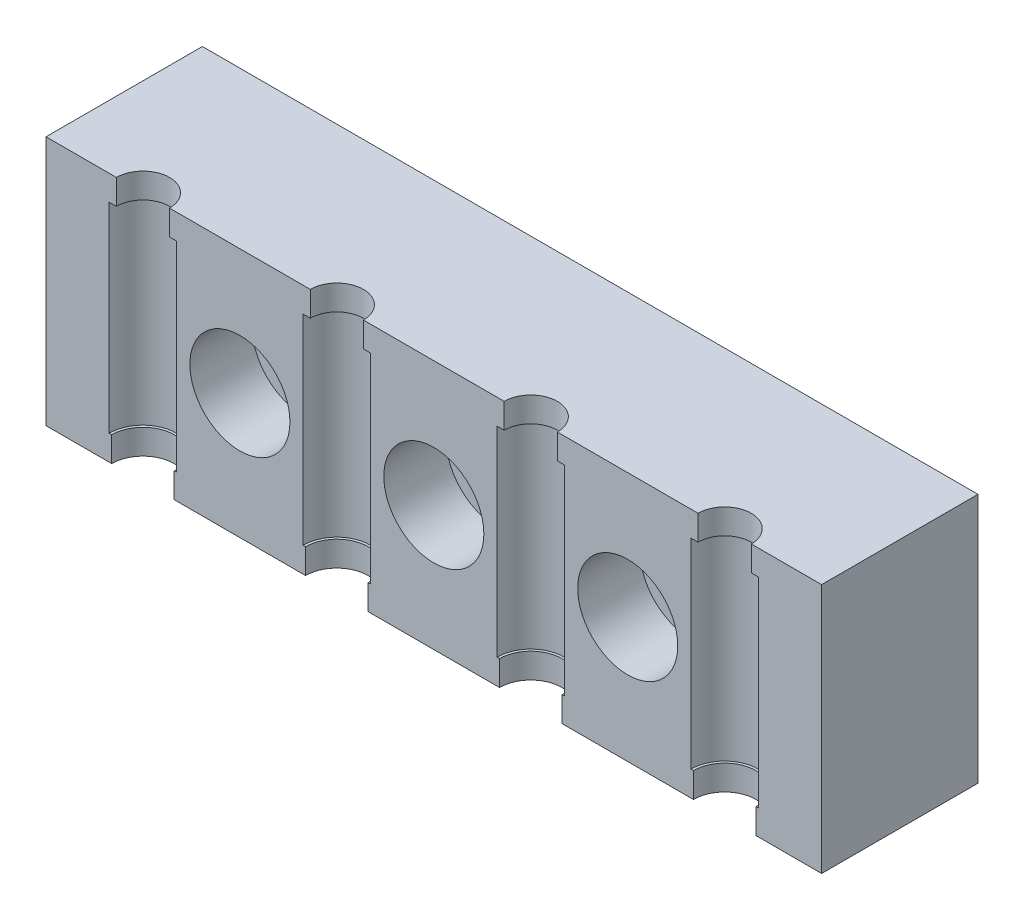
from build123d import *

# Parameters (mm, degrees)
WYCI_GNI_CIE1_DEPTH        = 62
SZKIC2_R                   = 2.125
WYTNIJ_WYCI_GNI_CIE1_DEPTH = 21
SZKIC3_R                   = 2.7
WYTNIJ_WYCI_GNI_CIE2_DEPTH = 16
SZKIC4_W                   = 5
SZKIC4_H                   = 2
WYTNIJ_WYCI_GNI_CIE3_DEPTH = 21
SFAZOWANIE1_SIZE           = 0.5
SZKIC5_R                   = 2.5
WYTNIJ_WYCI_GNI_CIE4_DEPTH = 16
SZKIC6_R                   = 4
WYTNIJ_WYCI_GNI_CIE5_DEPTH = 5
SZKIC7_R                   = 2.5
WYTNIJ_WYCI_GNI_CIE6_DEPTH = 10


with BuildPart() as part:
    # Szkic1 → Wyciągnięcie1 (new body)
    with BuildSketch(Plane(origin=(0, 0, 0), x_dir=(0, 0, -1), z_dir=(1, 0, 0))):
        Polygon((0, 0), (0, -20), (13, -20), (13, -15), (15, -15), (15, -5), (13, -5), (13, 0), align=None)
    extrude(amount=WYCI_GNI_CIE1_DEPTH)

    # Szkic2 → Wytnij-wyciągnięcie1 (cut, through all)
    with BuildSketch(Plane(origin=(0, 0, 0), x_dir=(-1, 0, 0), z_dir=(0, 1, 0))):
        with Locations((-7.75, 0)):
            Circle(SZKIC2_R)
        with Locations((-23.25, 0)):
            Circle(SZKIC2_R)
        with Locations((-38.75, 0)):
            Circle(SZKIC2_R)
        with Locations((-54.25, 0)):
            Circle(SZKIC2_R)
    extrude(amount=-WYTNIJ_WYCI_GNI_CIE1_DEPTH, mode=Mode.SUBTRACT)

    # Szkic3 → Wytnij-wyciągnięcie2 (cut)
    with BuildSketch(Plane(origin=(0, -2, 0), x_dir=(-1, 0, 0), z_dir=(0, 1, 0))):
        with Locations((-7.75, 0)):
            Circle(SZKIC3_R)
        with Locations((-23.25, 0)):
            Circle(SZKIC3_R)
        with Locations((-38.75, 0)):
            Circle(SZKIC3_R)
        with Locations((-54.25, 0)):
            Circle(SZKIC3_R)
    extrude(amount=-WYTNIJ_WYCI_GNI_CIE2_DEPTH, mode=Mode.SUBTRACT)

    # Szkic4 → Wytnij-wyciągnięcie3 (cut, through all)
    with BuildSketch(Plane(origin=(0, 0, 0), x_dir=(-1, 0, 0), z_dir=(0, 1, 0))):
        with Locations((-59.5, -14)):
            Rectangle(SZKIC4_W, SZKIC4_H)
        with Locations((-2.5, -14)):
            Rectangle(SZKIC4_W, SZKIC4_H)
    extrude(amount=-WYTNIJ_WYCI_GNI_CIE3_DEPTH, mode=Mode.SUBTRACT)

    # Sfazowanie1
    sfazowanie1_edges = [part.edges().sort_by_distance(p)[0] for p in [
        (31, -5, -15),
        (31, -15, -15),
        (57, -10, -15),
        (31, 0, -13),
        (62, -10, -13),
        (31, -20, -13),
        (5, -10, -15),
        (0, -10, -13),
    ]]
    chamfer(sfazowanie1_edges, length=SFAZOWANIE1_SIZE)

    # Szkic5 → Wytnij-wyciągnięcie4 (cut, through all)
    with BuildSketch(Plane.XY):
        with Locations((31, -10)):
            Circle(SZKIC5_R)
        with Locations((46.5, -10)):
            Circle(SZKIC5_R)
        with Locations((15.5, -10)):
            Circle(SZKIC5_R)
    extrude(amount=-WYTNIJ_WYCI_GNI_CIE4_DEPTH, mode=Mode.SUBTRACT)

    # Szkic6 → Wytnij-wyciągnięcie5 (cut)
    with BuildSketch(Plane.XY):
        with Locations((46.5, -10)):
            Circle(SZKIC6_R)
        with Locations((31, -10)):
            Circle(SZKIC6_R)
        with Locations((15.5, -10)):
            Circle(SZKIC6_R)
    extrude(amount=-WYTNIJ_WYCI_GNI_CIE5_DEPTH, mode=Mode.SUBTRACT)

    # Szkic7 → Wytnij-wyciągnięcie6 (cut)
    with BuildSketch(Plane.XZ.offset(20)):
        with Locations((7.75, 0)):
            Circle(SZKIC7_R)
        with Locations((23.25, 0)):
            Circle(SZKIC7_R)
        with Locations((38.75, 0)):
            Circle(SZKIC7_R)
        with Locations((54.25, 0)):
            Circle(SZKIC7_R)
    extrude(amount=-WYTNIJ_WYCI_GNI_CIE6_DEPTH, mode=Mode.SUBTRACT)


solid = part.part
